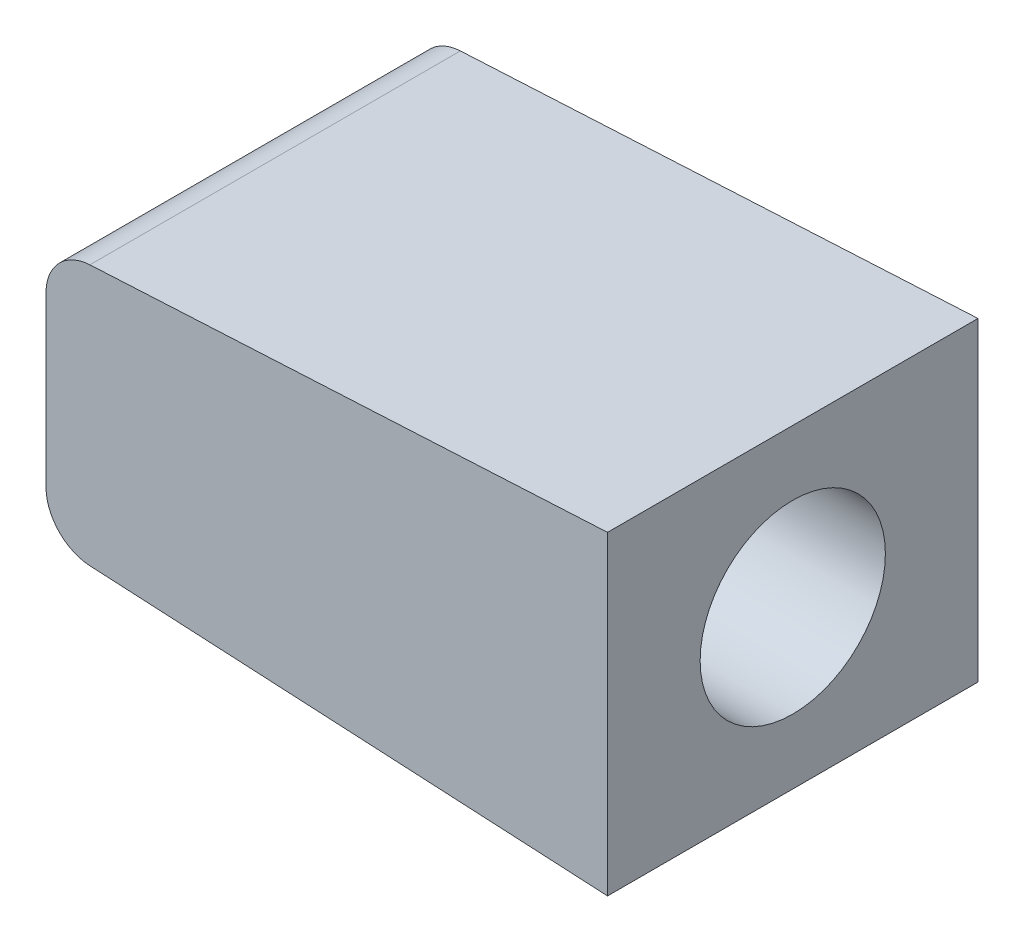
from build123d import *

# Parameters (mm, degrees)
RESSALTO_EXTRUS_O1_DEPTH = 8
ESBO_O3_R                = 2
CORTE_EXTRUS_O1_DEPTH    = 13.125139244


with BuildPart() as part:
    # Esboço2 → Ressalto-extrusão1 (new body)
    with BuildSketch(Plane.XY):
        with BuildLine():
            Line((42.125139244, 205.781065113), (30.947664044, 205.195278459))
            ThreePointArc((30.947664044, 205.195278459), (30.274625629, 204.8850035), (30, 204.196648925))
            Line((30, 204.196648925), (30, 200.565481301))
            ThreePointArc((30, 200.565481301), (30.274625629, 199.877126725), (30.947664044, 199.566851766))
            Line((30.947664044, 199.566851766), (42.125139244, 198.981065113))
            Line((42.125139244, 198.981065113), (42.125139244, 205.781065113))
        make_face()
    extrude(amount=-RESSALTO_EXTRUS_O1_DEPTH)

    # Esboço3 → Corte-extrusão1 (cut, through all)
    with BuildSketch(Plane(origin=(42.125139244, 0, 0), x_dir=(0, 0, -1), z_dir=(1, 0, 0))):
        with Locations((4, 202.381065113)):
            Circle(ESBO_O3_R)
    extrude(amount=-CORTE_EXTRUS_O1_DEPTH, mode=Mode.SUBTRACT)


solid = part.part
